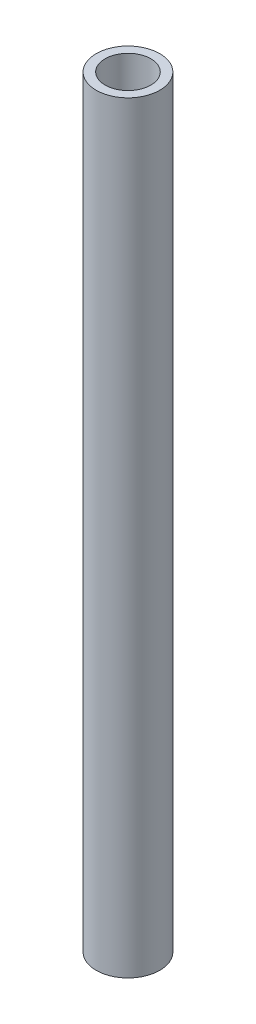
from build123d import *

# Parameters (mm, degrees)
SKETCH1_R           = 3.175
SKETCH1_R_2         = 2.286
BOSS_EXTRUDE1_DEPTH = 76.2


with BuildPart() as part:
    # Sketch1 → Boss-Extrude1 (new body)
    with BuildSketch(Plane(origin=(0, 0, 0), x_dir=(1, 0, 0), z_dir=(0, 1, 0))):
        Circle(SKETCH1_R)
        Circle(SKETCH1_R_2, mode=Mode.SUBTRACT)
    extrude(amount=BOSS_EXTRUDE1_DEPTH)


solid = part.part
